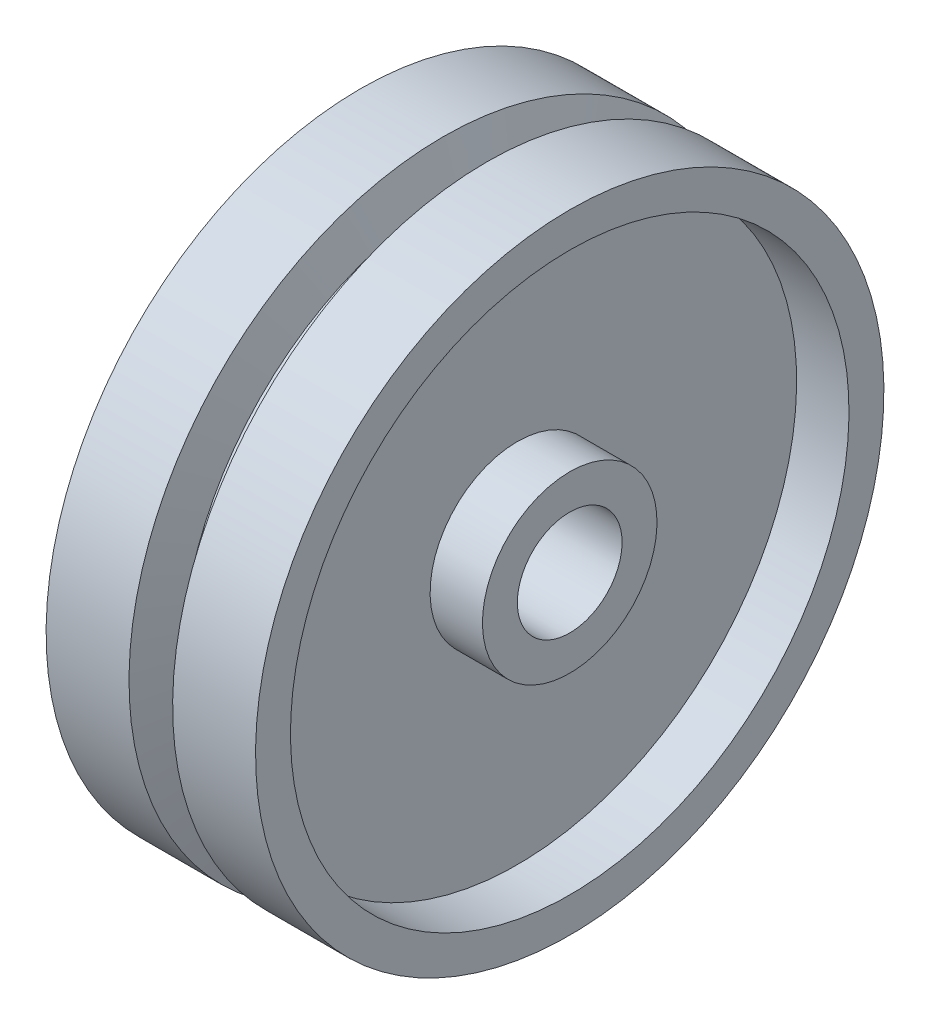
from build123d import *


with BuildPart() as part:
    # Croquis1 → Revolución1 (revolve)
    with BuildSketch(Plane.XY):
        Polygon((0, 3), (-4.75, 3), (-5.5, 5.25), (-6.5, 5.25), (-7.25, 3), (-12, 3), (-12, 5), (-9, 5), (-9, 16), (-12, 16), (-12, 18), (-7.25, 18), (-6.5, 15.75), (-5.5, 15.75), (-4.75, 18), (0, 18), (0, 16), (-3, 16), (-3, 5), (0, 5), align=None)
    revolve(axis=Axis((0, 0, 0), (-1, 0, 0)))


solid = part.part
